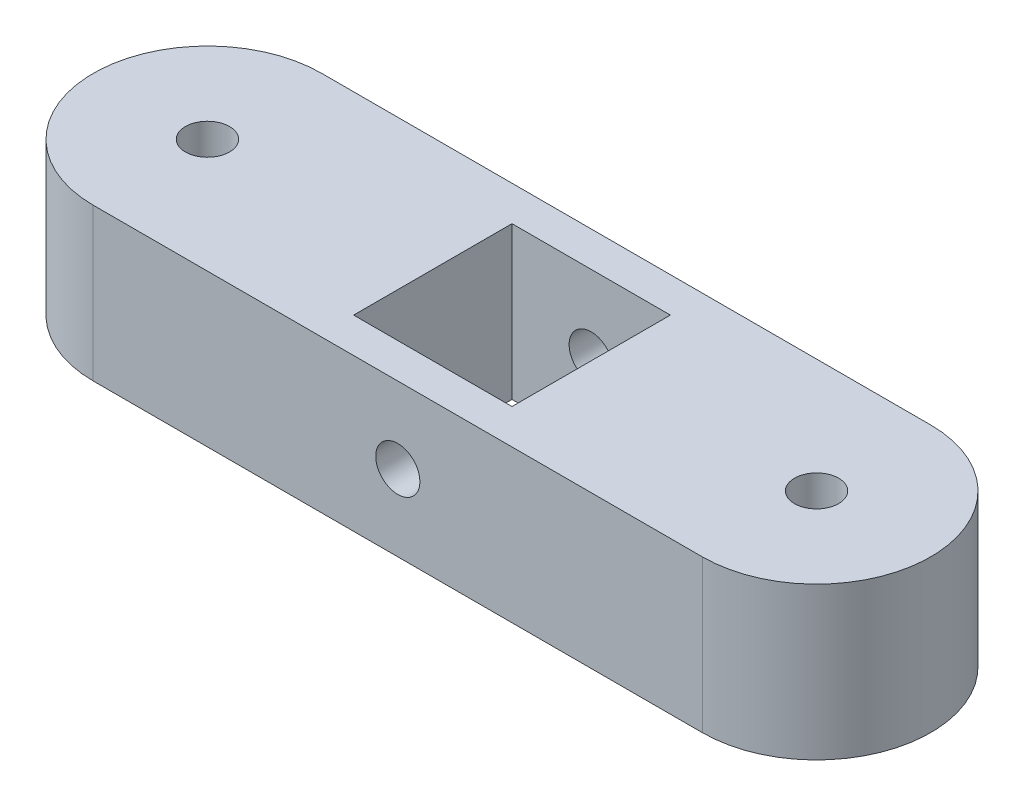
from build123d import *

# Parameters (mm, degrees)
SKETCH1_R           = 3.683
SKETCH1_W           = 26.416
SKETCH1_H           = 26.416
BOSS_EXTRUDE1_DEPTH = 25.4
SKETCH2_R           = 3.683
CUT_EXTRUDE1_DEPTH  = 39.1


with BuildPart() as part:
    # Sketch1 → Boss-Extrude1 (new body)
    with BuildSketch(Plane(origin=(0, 0, 0), x_dir=(1, 0, 0), z_dir=(0, 1, 0))):
        with BuildLine():
            Line((-50.8, 19.05), (50.8, 19.05))
            ThreePointArc((50.8, 19.05), (69.85, 0), (50.8, -19.05))
            Line((50.8, -19.05), (-50.8, -19.05))
            ThreePointArc((-50.8, -19.05), (-69.85, 0), (-50.8, 19.05))
        make_face()
        with Locations((-50.8, 0)):
            Circle(SKETCH1_R, mode=Mode.SUBTRACT)
        with Locations((50.8, 0)):
            Circle(SKETCH1_R, mode=Mode.SUBTRACT)
        Rectangle(SKETCH1_W, SKETCH1_H, mode=Mode.SUBTRACT)
    extrude(amount=BOSS_EXTRUDE1_DEPTH)

    # Sketch2 → Cut-Extrude1 (cut, through all)
    with BuildSketch(Plane.XY.offset(19.05)):
        with Locations((0, 12.7)):
            Circle(SKETCH2_R)
    extrude(amount=-CUT_EXTRUDE1_DEPTH, mode=Mode.SUBTRACT)


solid = part.part
